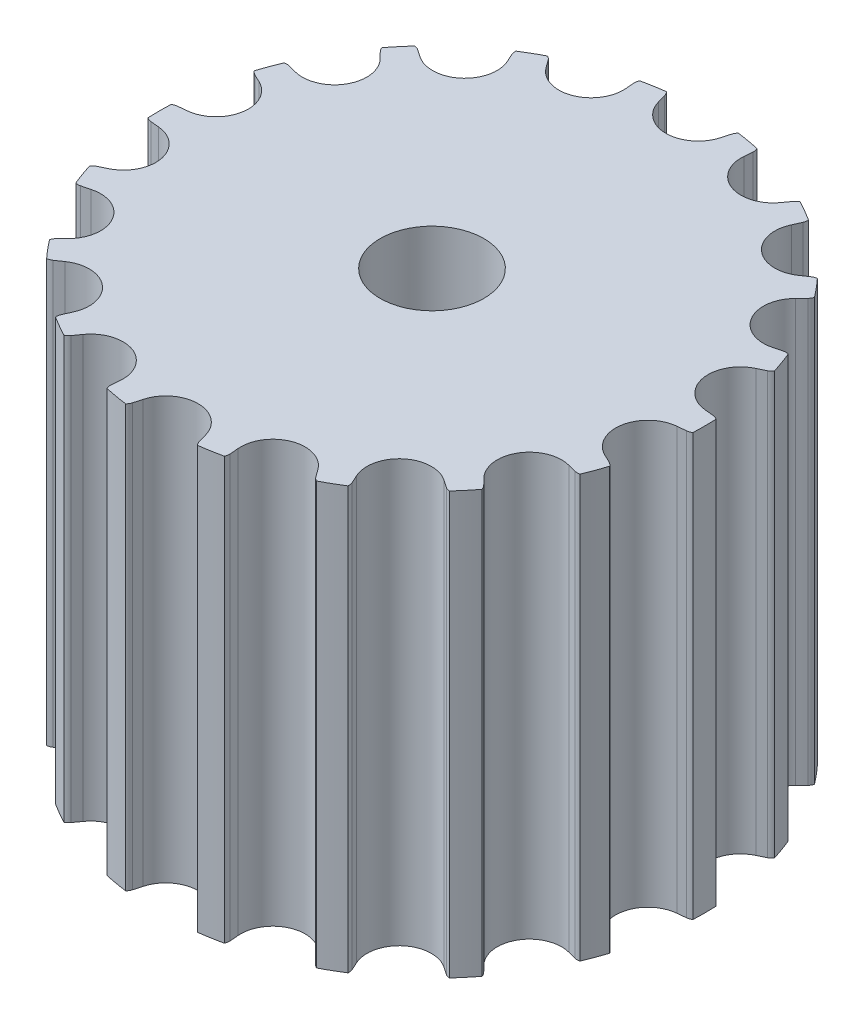
from build123d import *

# Parameters (mm, degrees)
SKETCH1_R               = 8.213367202
TOOTHOD_DEPTH           = 6.35
TOOTHPROFILE_DEPTH      = 7.35
TOOTHPATTERN_COUNT      = 18
SKETCH7_R               = 1.5625
BORE_DEPTH              = 8.62
BORE_DEPTH_BACK         = 8.62
SKETCH11_W              = 19.982734404
SKETCH11_H              = 1.27
CUT_EXTRUDE2_DEPTH      = 10.991367202
CUT_EXTRUDE2_DEPTH_BACK = 10.991367202


with BuildPart() as part:
    # Sketch1 → ToothOD (new body, symmetric)
    with BuildSketch(Plane(origin=(0, 0, 0), x_dir=(1, 0, 0), z_dir=(0, 1, 0))):
        Circle(SKETCH1_R)
    extrude(amount=TOOTHOD_DEPTH, both=True)

    # Sketch2 → ToothProfile (cut, symmetric)
    with BuildSketch(Plane(origin=(0, 0, 0), x_dir=(1, 0, 0), z_dir=(0, 1, 0))):
        with BuildLine():
            ThreePointArc((-0.937033068, 7.763429198), (-0.590385173, 7.245254588), (0, 7.044967202))
            ThreePointArc((0, 7.044967202), (0.590385173, 7.245254588), (0.937033068, 7.763429198))
            ThreePointArc((0.937033068, 7.763429198), (0.971699064, 7.88954066), (1.007805813, 8.015247202))
            ThreePointArc((1.007805813, 8.015247202), (1.037242296, 8.083128985), (1.082411127, 8.141731201))
            ThreePointArc((1.082411127, 8.141731201), (0, 8.213367202), (-1.082411127, 8.141731201))
            ThreePointArc((-1.082411127, 8.141731201), (-1.037242296, 8.083128985), (-1.007805813, 8.015247202))
            ThreePointArc((-1.007805813, 8.015247202), (-0.971699064, 7.88954066), (-0.937033068, 7.763429198))
        make_face()
    toothprofile = extrude(amount=TOOTHPROFILE_DEPTH, both=True, mode=Mode.SUBTRACT)

    # ToothPattern: ToothProfile ×18 about axis
    toothpattern_axis = Axis((0, 0, 0), (0, 1, 0))
    for i in range(1, TOOTHPATTERN_COUNT):
        add(toothprofile.rotate(toothpattern_axis, i * 360 / TOOTHPATTERN_COUNT), mode=Mode.SUBTRACT)

    # Sketch4 → Flange (revolve)
    with BuildSketch(Plane.XY):
        with BuildLine():
            Line((0, -6.35), (8.467367202, -6.35))
            ThreePointArc((8.467367202, -6.35), (8.697013823, -6.385951298), (8.92243953, -6.442637424))
            ThreePointArc((8.92243953, -6.442637424), (9.490168107, -6.724197125), (9.991367202, -7.112))
            Line((9.991367202, -7.112), (9.991367202, -7.62))
            Line((9.991367202, -7.62), (0, -7.62))
            Line((0, -7.62), (0, -6.35))
        make_face()
        with BuildLine():
            Line((9.991367202, 7.62), (9.991367202, 7.112))
            ThreePointArc((9.991367202, 7.112), (9.490168107, 6.724197125), (8.92243953, 6.442637424))
            ThreePointArc((8.92243953, 6.442637424), (8.697013823, 6.385951298), (8.467367202, 6.35))
            Line((8.467367202, 6.35), (0, 6.35))
            Line((0, 6.35), (0, 7.62))
            Line((0, 7.62), (9.991367202, 7.62))
        make_face()
    revolve(axis=Axis((0, 8.73125, 0), (0, -1, 0)))

    # Sketch7 → Bore (cut, two sides)
    with BuildSketch(Plane.XZ) as bore_sk:
        Circle(SKETCH7_R)
    extrude(amount=BORE_DEPTH, mode=Mode.SUBTRACT)
    extrude(bore_sk.sketch, amount=-BORE_DEPTH_BACK, mode=Mode.SUBTRACT)

    # Sketch11 → Cut-Extrude2 (cut, two sides)
    with BuildSketch(Plane.XY) as cut_extrude2_sk:
        with Locations((0, 6.985)):
            Rectangle(SKETCH11_W, SKETCH11_H)
        with Locations((0, -6.985)):
            Rectangle(SKETCH11_W, SKETCH11_H)
    extrude(amount=CUT_EXTRUDE2_DEPTH, mode=Mode.SUBTRACT)
    extrude(cut_extrude2_sk.sketch, amount=-CUT_EXTRUDE2_DEPTH_BACK, mode=Mode.SUBTRACT)


solid = part.part
